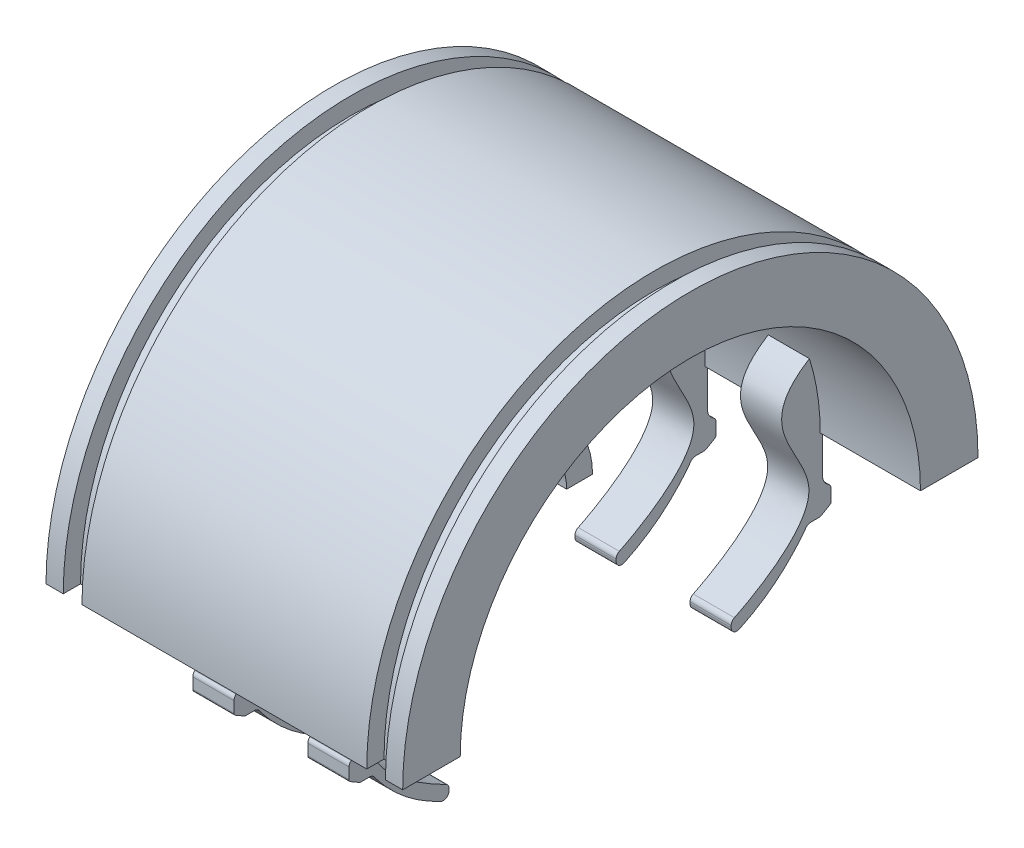
from build123d import *

# Parameters (mm, degrees)
REVOLVE1_ANGLE       = 180
BOSS_EXTRUDE1_DEPTH  = 31
CUT_EXTRUDE2_DEPTH   = 74
CIRPATTERN2_COUNT    = 6
SKETCH2_R            = 3.91275
SKETCH2_R_2          = 2.80275
CUT_EXTRUDE4_DEPTH   = 8.72
BOSS_EXTRUDE4_DEPTH  = 3.5775
MIRROR6_COPY_1_DEPTH = 3.5775
FILLET7_R            = 1
FILLET8_R            = 2
FILLET9_R            = 1
FILLET10_R           = 1
FILLET11_R           = 0.5


with BuildPart() as part:
    # Sketch1 → Revolve1 (revolve)
    with BuildSketch(Plane(origin=(0, 0, 0), x_dir=(1, 0, 0), z_dir=(0, 1, 0))):
        with BuildLine():
            Line((24.75, 47), (28, 47))
            Line((28, 47), (28, 50))
            Line((28, 50), (31, 50))
            Line((31, 50), (31, 40))
            Line((31, 40), (-26, 40))
            add(Edge.make_bspline(
                [(-26, 40), (-27.013739482, 36.809226409), (-29.345099443, 27.828113636), (-24.523456801, 15.394699457), (-15.526264119, 14.868541835), (-9.946885113, 14)],
                knots=[0, 0, 0, 0, 0.285238859, 0.456571244, 0.779817638, 0.779817638, 0.779817638, 0.779817638], degree=3))
            Line((-9.946885113, 14), (-10, 9.5))
            add(Edge.make_bspline(
                [(-31, 40), (-32.939614555, 37.540591148), (-36.933922801, 27.582274875), (-30.082407751, 11.775662378), (-17.92187093, 9.5), (-10, 9.5)],
                knots=[0, 0, 0, 0, 0.268184782, 0.444494999, 0.822560414, 0.822560414, 0.822560414, 0.822560414], degree=3))
            Line((-31, 40), (-31, 50))
            Line((-31, 50), (-28, 50))
            Line((-28, 50), (-28, 47))
            Line((-28, 47), (-24.75, 47))
            Line((-24.75, 47), (-24.75, 50))
            Line((-24.75, 50), (24.75, 50))
            Line((24.75, 50), (24.75, 47))
        make_face()
    revolve(axis=Axis((0, 0, 0), (1, 0, 0)), revolution_arc=REVOLVE1_ANGLE)

    # Sketch6 → Boss-Extrude1 (add)
    with BuildSketch(Plane(origin=(0, 0, 0), x_dir=(0, 0, -1), z_dir=(1, 0, 0))):
        with BuildLine():
            Line((-14, 0), (-9.5, 0))
            ThreePointArc((-9.5, 0), (0, 9.5), (9.5, 0))
            Line((9.5, 0), (14, 0))
            ThreePointArc((14, 0), (0, 14), (-14, 0))
        make_face()
    extrude(amount=-BOSS_EXTRUDE1_DEPTH)

    # Sketch7 → Cut-Extrude2 (cut)
    with BuildSketch(Plane(origin=(31, 0, 0), x_dir=(0, 0, -1), z_dir=(1, 0, 0))):
        with BuildLine():
            Line((4.788282007, 13.155696691), (13.680805733, 37.587704831))
            ThreePointArc((13.680805733, 37.587704831), (0, 40), (-13.680805733, 37.587704831))
            Line((-13.680805733, 37.587704831), (-4.788282007, 13.155696691))
            ThreePointArc((-4.788282007, 13.155696691), (0, 14), (4.788282007, 13.155696691))
        make_face()
    cut_extrude2 = extrude(amount=-CUT_EXTRUDE2_DEPTH, mode=Mode.SUBTRACT)

    # CirPattern2: Cut-Extrude2 ×6 about axis
    cirpattern2_axis = Axis((0, 0, 0), (1, 0, 0))
    for i in range(1, CIRPATTERN2_COUNT):
        add(cut_extrude2.rotate(cirpattern2_axis, i * 360 / CIRPATTERN2_COUNT), mode=Mode.SUBTRACT)

    # Sketch2 → Cut-Extrude4 (cut)
    with BuildSketch(Plane(origin=(0, 0, 0), x_dir=(-1, 0, 0), z_dir=(0, -1, 0))):
        with Locations((0, -45)):
            Circle(SKETCH2_R)
        with Locations((19.991543972, -45)):
            Circle(SKETCH2_R_2)
        with Locations((-19.991543972, -45)):
            Circle(SKETCH2_R_2)
    cut_extrude4 = extrude(amount=-CUT_EXTRUDE4_DEPTH, mode=Mode.SUBTRACT)

    # Mirror1: Cut-Extrude4 across plane
    add(cut_extrude4.mirror(Plane.XY), mode=Mode.SUBTRACT)

    # Sketch13 → Boss-Extrude4 (add, symmetric)
    with BuildSketch(Plane(origin=(10, 0, 0), x_dir=(0, 0, -1), z_dir=(1, 0, 0))):
        with BuildLine():
            Line((-40, 0), (-40.405, 0))
            Line((-40.405, 0), (-40.405, -7.6))
            Line((-40.405, -7.6), (-41.905, -8.858649447))
            Line((-41.905, -8.858649447), (-41.905, -11.513649447))
            Line((-41.905, -11.513649447), (-40, -12.61350171))
            Line((-40, -12.61350171), (-37.823356538, -12.61350171))
            add(Edge.make_bspline(
                [(-24.520379137, -23.11350171), (-32.734104628, -19.717610298), (-37.823356538, -12.61350171)],
                knots=[0, 0, 0, 1, 1, 1], degree=2))
            Line((-24.520379137, -23.11350171), (-24.520379137, -20.61350171))
            add(Edge.make_bspline(
                [(-38.112765223, 12.141545496), (-27.176299866, 5.358860991), (-48.400437079, -7.835754971), (-28.130657702, -18.911245963), (-24.520379137, -20.61350171)],
                knots=[0, 0, 0, 0, 0.525361661, 1, 1, 1, 1], degree=3))
            ThreePointArc((-38.112765223, 12.141545496), (-39.52537545, 6.143671177), (-40, 0))
        make_face()
    boss_extrude4 = extrude(amount=BOSS_EXTRUDE4_DEPTH, both=True)

    # Mirror5: Boss-Extrude4 across plane
    add(boss_extrude4.mirror(Plane(origin=(0, 0, 0), x_dir=(0, 0, 1), z_dir=(1, 0, 0))))

    # Mirror6: Boss-Extrude4 across plane
    add(boss_extrude4.mirror(Plane.XY))

    # Mirror6 copy 1 sketch → Mirror6 copy 1 (add, symmetric)
    with BuildSketch(Plane.ZY.offset(10)):
        with BuildLine():
            Line((-40, 0), (-40.405, 0))
            Line((-40.405, 0), (-40.405, -7.6))
            Line((-40.405, -7.6), (-41.905, -8.858649447))
            Line((-41.905, -8.858649447), (-41.905, -11.513649447))
            Line((-41.905, -11.513649447), (-40, -12.61350171))
            Line((-40, -12.61350171), (-37.823356538, -12.61350171))
            add(Edge.make_bspline(
                [(-24.520379137, -23.11350171), (-32.734104628, -19.717610298), (-37.823356538, -12.61350171)],
                knots=[0, 0, 0, 1, 1, 1], degree=2))
            Line((-24.520379137, -23.11350171), (-24.520379137, -20.61350171))
            add(Edge.make_bspline(
                [(-38.112765223, 12.141545496), (-27.176299866, 5.358860991), (-48.400437079, -7.835754971), (-28.130657702, -18.911245963), (-24.520379137, -20.61350171)],
                knots=[0, 0, 0, 0, 0.525361661, 1, 1, 1, 1], degree=3))
            ThreePointArc((-38.112765223, 12.141545496), (-39.52537545, 6.143671177), (-40, 0))
        make_face()
    extrude(amount=MIRROR6_COPY_1_DEPTH, both=True)

    # Fillet7
    fillet7_edges = [part.edges().sort_by_distance(p)[0] for p in [
        (-8.21125, -20.61350171, -24.520379137),
        (-11.78875, -23.11350171, -24.520379137),
        (11.78875, -20.61350171, -24.520379137),
        (8.21125, -23.11350171, -24.520379137),
        (-11.78875, -23.11350171, 24.520379137),
        (-11.78875, -20.61350171, 24.520379137),
        (8.21125, -23.11350171, 24.520379137),
        (8.21125, -20.61350171, 24.520379137),
    ]]
    fillet(fillet7_edges, radius=FILLET7_R)

    # Fillet8
    fillet8_edges = [part.edges().sort_by_distance(p)[0] for p in [
        (10, -7.6, 40.405),
        (-10, -7.6, 40.405),
        (10, -7.6, -40.405),
        (-10, -7.6, -40.405),
    ]]
    fillet(fillet8_edges, radius=FILLET8_R)

    # Fillet9
    fillet9_edges = [part.edges().sort_by_distance(p)[0] for p in [
        (10, -8.858649447, 41.905),
        (-10, -8.858649447, 41.905),
        (10, -8.858649447, -41.905),
        (-10, -8.858649447, -41.905),
    ]]
    fillet(fillet9_edges, radius=FILLET9_R)

    # Fillet10
    fillet10_edges = [part.edges().sort_by_distance(p)[0] for p in [
        (8.21125, -12.61350171, 37.823356538),
        (-8.21125, -12.61350171, 37.823356538),
        (8.21125, -12.61350171, -37.823356538),
        (-8.21125, -12.61350171, -37.823356538),
    ]]
    fillet(fillet10_edges, radius=FILLET10_R)

    # Fillet11
    fillet11_edges = [part.edges().sort_by_distance(p)[0] for p in [
        (10, -11.513649447, 41.905),
        (10, -12.61350171, 40),
        (-10, -12.61350171, 40),
        (-10, -11.513649447, 41.905),
        (10, -12.61350171, -40),
        (10, -11.513649447, -41.905),
        (-10, -11.513649447, -41.905),
        (-10, -12.61350171, -40),
    ]]
    fillet(fillet11_edges, radius=FILLET11_R)


solid = part.part
